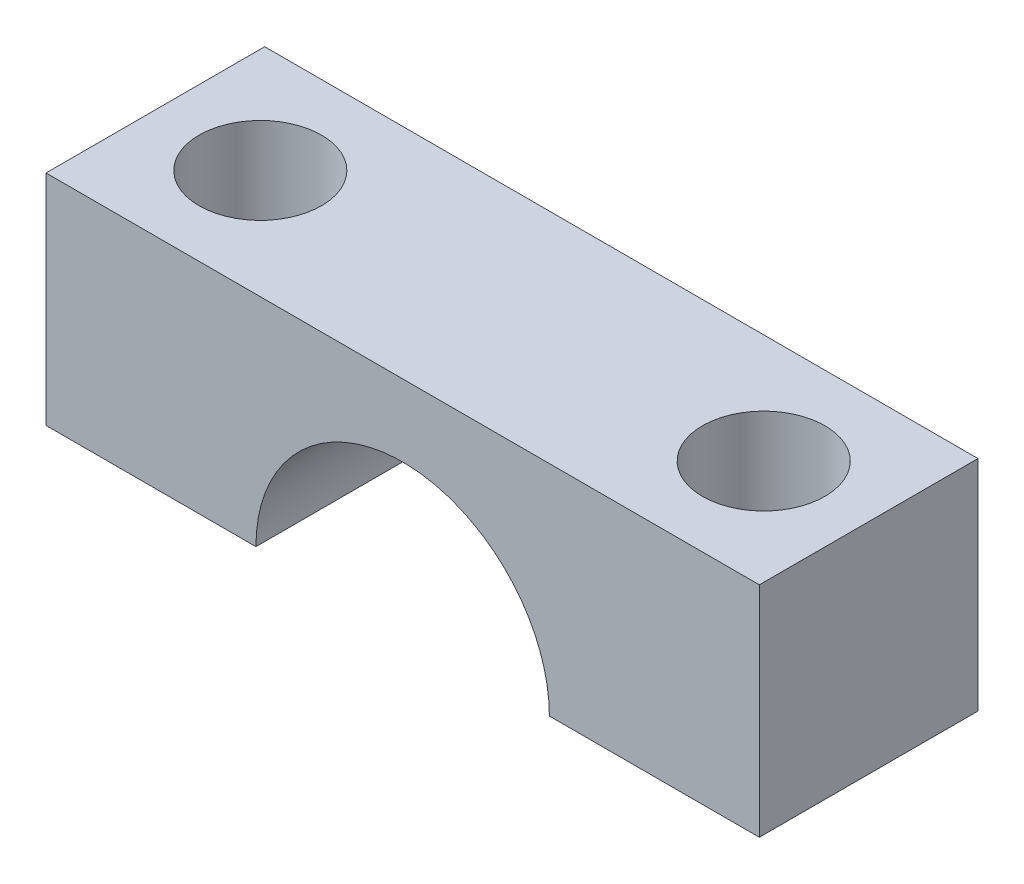
from build123d import *

# Parameters (mm, degrees)
SKETCH1_W                = 16.31
SKETCH1_H                = 5
BOSS_EXTRUDE3_DEPTH      = 5
CUT_EXTRUDE9_DEPTH       = 5
CUT_EXTRUDE10_DEPTH      = 2.5
CUT_EXTRUDE10_DEPTH_BACK = 2.5
SKETCH4_R                = 1.4


with BuildPart() as part:
    # Sketch1 → Boss-Extrude3 (new body)
    with BuildSketch(Plane.XY):
        Rectangle(SKETCH1_W, SKETCH1_H)
    extrude(amount=-BOSS_EXTRUDE3_DEPTH)

    # Sketch3 → Cut-Extrude9 (cut)
    with BuildSketch(Plane.XY):
        with BuildLine():
            Line((-3.355, -2.5), (3.355, -2.5))
            ThreePointArc((3.355, -2.5), (0, 0.855), (-3.355, -2.5))
        make_face()
    extrude(amount=-CUT_EXTRUDE9_DEPTH, mode=Mode.SUBTRACT)

    # Sketch4 → Cut-Extrude10 (cut, two sides: drawn at the far end of the back side and taken through both)
    with BuildSketch(Plane(origin=(0, 0, 0), x_dir=(1, 0, 0), z_dir=(0, 1, 0)).offset(-CUT_EXTRUDE10_DEPTH_BACK)):
        with Locations((-5.755, 2.5)):
            Circle(SKETCH4_R)
        with Locations((5.755, 2.5)):
            Circle(SKETCH4_R)
    extrude(amount=CUT_EXTRUDE10_DEPTH + CUT_EXTRUDE10_DEPTH_BACK, mode=Mode.SUBTRACT)


solid = part.part
